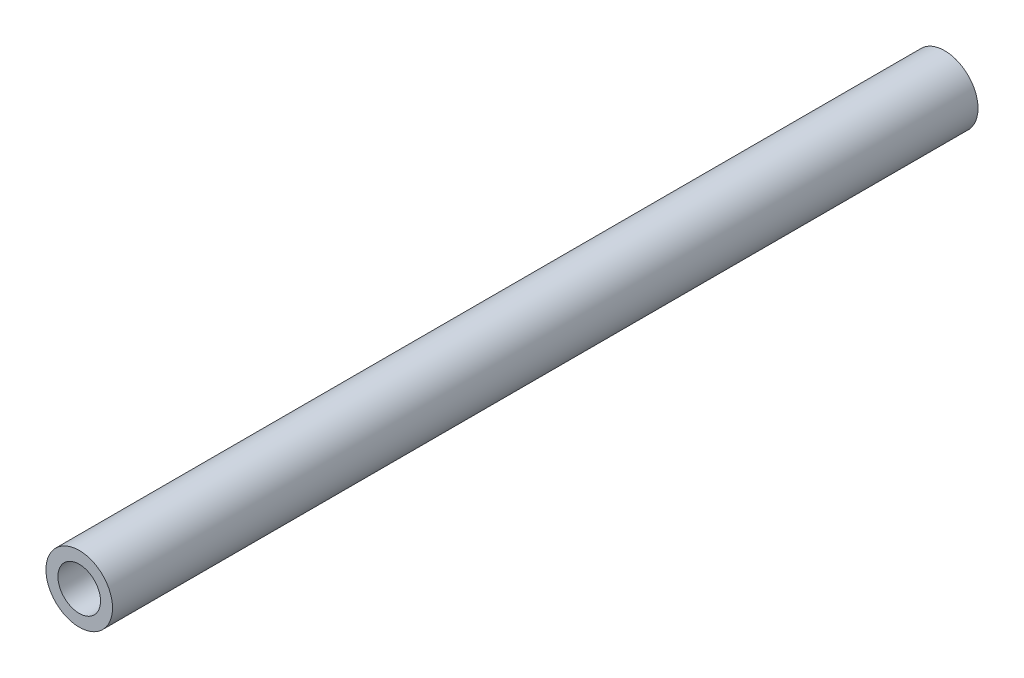
from build123d import *

# Parameters (mm, degrees)
SKETCH1_R           = 2.5
SKETCH1_R_2         = 1.6
BOSS_EXTRUDE2_DEPTH = 65


with BuildPart() as part:
    # Sketch1 → Boss-Extrude2 (new body)
    with BuildSketch(Plane.XY):
        Circle(SKETCH1_R)
        Circle(SKETCH1_R_2, mode=Mode.SUBTRACT)
    extrude(amount=BOSS_EXTRUDE2_DEPTH)


solid = part.part
